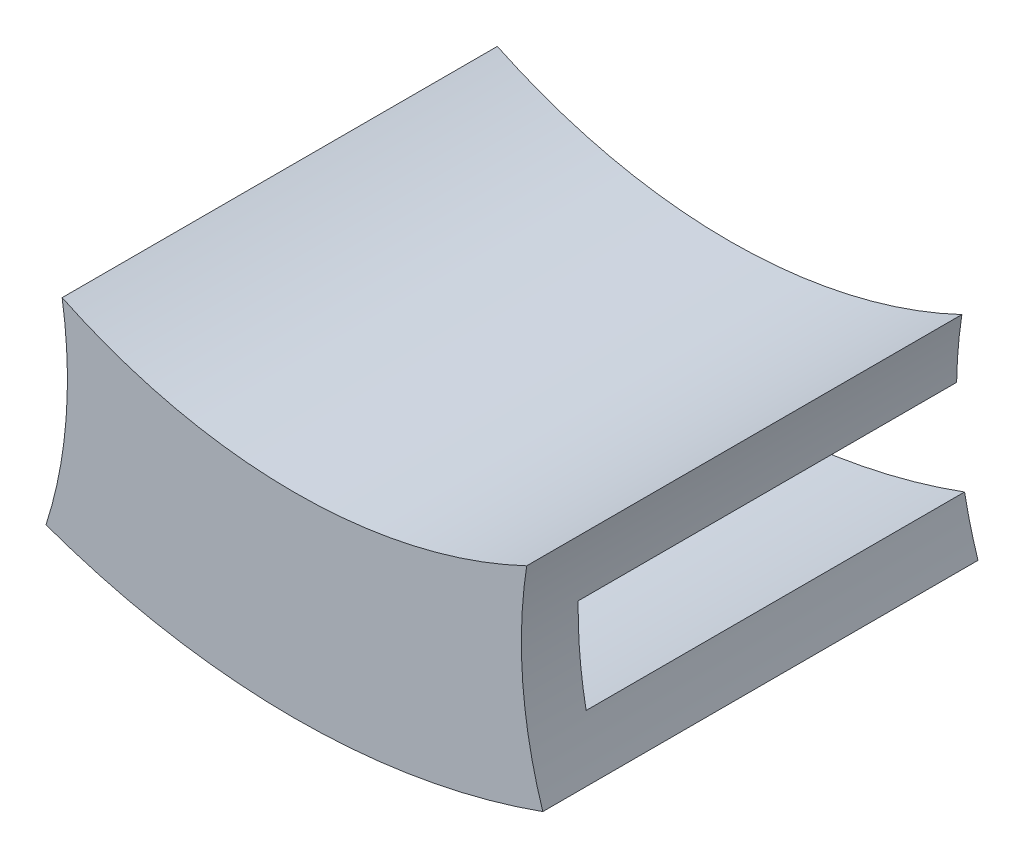
from build123d import *

# Parameters (mm, degrees)
BOSS_EXTRUDE1_DEPTH = 3
BOSS_EXTRUDE2_DEPTH = 20


with BuildPart() as part:
    # Sketch1 → Boss-Extrude1 (new body)
    with BuildSketch(Plane.XY):
        with BuildLine():
            ThreePointArc((12.275451386, 39.110148544), (12.067880772, 33.648168724), (13.127719813, 28.28598164))
            ThreePointArc((13.127719813, 28.28598164), (-5.7809e-05, 26.00056132), (-13.127971261, 28.285201272))
            ThreePointArc((-13.127971261, 28.285201272), (-12.06796259, 33.647129894), (-12.275256819, 39.10889939))
            ThreePointArc((-12.275256819, 39.10889939), (0.000238569, 36.332719941), (12.275451386, 39.110148544))
        make_face()
    extrude(amount=BOSS_EXTRUDE1_DEPTH)

    # Sketch2 → Boss-Extrude2 (add)
    with BuildSketch(Plane(origin=(0, 0, 0), x_dir=(-1, 0, 0), z_dir=(0, 0, -1))):
        with BuildLine():
            ThreePointArc((-0.000238569, 33.482719941), (6.116423648, 34.084515432), (11.998357864, 35.867368305))
            ThreePointArc((11.998357864, 35.867368305), (12.080645356, 37.492931332), (12.275256819, 39.10889939))
            ThreePointArc((12.275256819, 39.10889939), (-0.000238569, 36.332719941), (-12.275451386, 39.110148544))
            ThreePointArc((-12.275451386, 39.110148544), (-12.080742195, 37.494064654), (-11.998373995, 35.868378864))
            ThreePointArc((-11.998373995, 35.868378864), (-6.116717522, 34.085055957), (-0.000238569, 33.482719941))
        make_face()
        with BuildLine():
            ThreePointArc((-13.127719813, 28.28598164), (5.7809e-05, 26.00056132), (13.127971261, 28.285201272))
            ThreePointArc((13.127971261, 28.285201272), (12.730383089, 29.661389101), (12.417381714, 31.059244398))
            ThreePointArc((12.417381714, 31.059244398), (5.905e-06, 28.850561321), (-12.417221823, 31.060076762))
            ThreePointArc((-12.417221823, 31.060076762), (-12.730176217, 29.662196758), (-13.127719813, 28.28598164))
        make_face()
    extrude(amount=BOSS_EXTRUDE2_DEPTH)


solid = part.part
